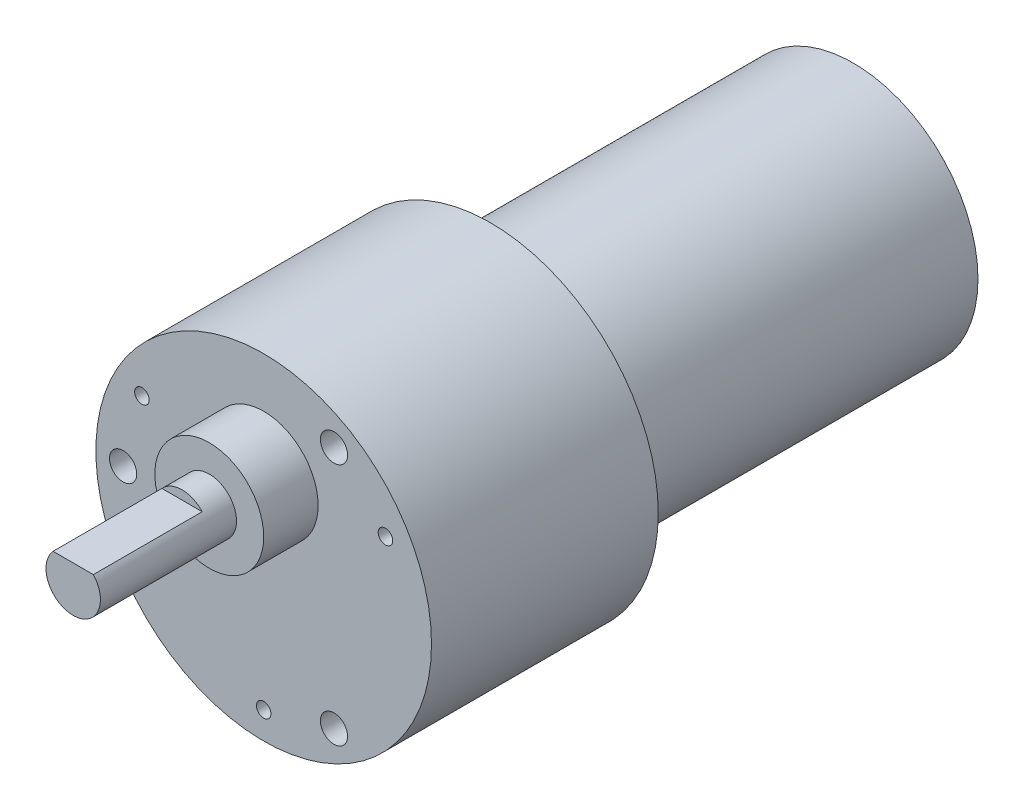
from build123d import *

# Parameters (mm, degrees)
SKETCH_2_R          = 13.75
EXTRUDE_1_DEPTH     = 40
SKETCH_3_R          = 18.5
EXTRUDE_2_DEPTH     = 25
CHAMFER_1_SIZE      = 2
SKETCH_4_R          = 6
EXTRUDE_3_DEPTH     = 6
SKETCH_5_R          = 3
EXTRUDE_4_DEPTH     = 15
CUT_EXTRUDE_1_DEPTH = 12
SKETCH_7_R          = 1.5
CUT_EXTRUDE_2_DEPTH = 6
SKETCH_8_R          = 1.5
CUT_EXTRUDE_3_DEPTH = 6
SKETCH_10_R         = 1.5
CUT_EXTRUDE_4_DEPTH = 6
SKETCH_11_R         = 5.1
EXTRUDE_5_DEPTH     = 3
M2X0_4_1_D          = 1.6
M2X0_4_1_DEPTH      = 6
M2X0_4_1_TIP        = 0.480688495


with BuildPart() as part:
    # ｽｹｯﾁ2 → ﾎﾞｽ - 押し出し1 (new body)
    with BuildSketch(Plane.XY):
        Circle(SKETCH_2_R)
    extrude(amount=EXTRUDE_1_DEPTH)

    # ｽｹｯﾁ3 → ﾎﾞｽ - 押し出し2 (add)
    with BuildSketch(Plane.XY.offset(40)):
        Circle(SKETCH_3_R)
    extrude(amount=EXTRUDE_2_DEPTH)

    # 面取り1
    chamfer_1_edges = [part.edges().sort_by_distance(p)[0] for p in [
        (-13.75, 0, 40),
    ]]
    chamfer(chamfer_1_edges, length=CHAMFER_1_SIZE)

    # ｽｹｯﾁ4 → ﾎﾞｽ - 押し出し3 (add)
    with BuildSketch(Plane.XY.offset(65)):
        with Locations((0, 7)):
            Circle(SKETCH_4_R)
    extrude(amount=EXTRUDE_3_DEPTH)

    # ｽｹｯﾁ5 → ﾎﾞｽ - 押し出し4 (add)
    with BuildSketch(Plane.XY.offset(71)):
        with Locations((0, 7)):
            Circle(SKETCH_5_R)
    extrude(amount=EXTRUDE_4_DEPTH)

    # ｽｹｯﾁ6 → ｶｯﾄ - 押し出し1 (cut)
    with BuildSketch(Plane.XY.offset(86)):
        with BuildLine():
            Line((-2.222509648, 9.015056045), (2.222509648, 9.015056045))
            ThreePointArc((2.222509648, 9.015056045), (0, 10), (-2.222509648, 9.015056045))
        make_face()
    extrude(amount=-CUT_EXTRUDE_1_DEPTH, mode=Mode.SUBTRACT)

    # ｽｹｯﾁ7 → ｶｯﾄ - 押し出し2 (cut)
    with BuildSketch(Plane.XY.offset(65)):
        with Locations((-15.5, 0)):
            Circle(SKETCH_7_R)
    extrude(amount=-CUT_EXTRUDE_2_DEPTH, mode=Mode.SUBTRACT)

    # ｽｹｯﾁ8 → ｶｯﾄ - 押し出し3 (cut)
    with BuildSketch(Plane.XY.offset(65)):
        with Locations((7.75, -13.423393759)):
            Circle(SKETCH_8_R)
    extrude(amount=-CUT_EXTRUDE_3_DEPTH, mode=Mode.SUBTRACT)

    # ｽｹｯﾁ10 → ｶｯﾄ - 押し出し4 (cut)
    with BuildSketch(Plane.XY.offset(65)):
        with Locations((7.75, 13.423393759)):
            Circle(SKETCH_10_R)
    extrude(amount=-CUT_EXTRUDE_4_DEPTH, mode=Mode.SUBTRACT)

    # ｽｹｯﾁ11 → ﾎﾞｽ - 押し出し5 (add)
    with BuildSketch(Plane(origin=(0, 0, 0), x_dir=(-1, 0, 0), z_dir=(0, 0, -1))):
        Circle(SKETCH_11_R)
    extrude(amount=EXTRUDE_5_DEPTH)

    # M2x0.4 ねじ穴1
    with Locations(Plane.XY.offset(65)):
        with Locations((-13.423393759, 7.75), (0, -15.5), (13.423393759, 7.75)):
            Hole(M2X0_4_1_D / 2, depth=M2X0_4_1_DEPTH)
            with Locations((0, 0, -(M2X0_4_1_DEPTH + M2X0_4_1_TIP / 2))):  # 118° drill point
                Cone(0, M2X0_4_1_D / 2, M2X0_4_1_TIP, mode=Mode.SUBTRACT)


solid = part.part
